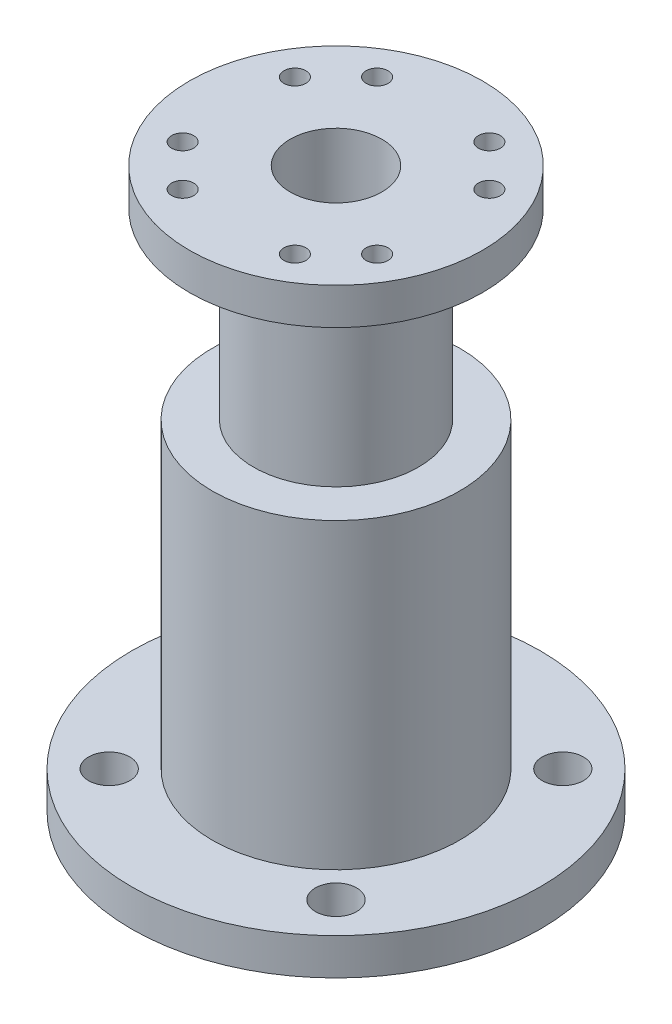
from build123d import *

# Parameters (mm, degrees)
SKETCH2_R                = 22.3
SKETCH2_R_2              = 13.5
BOSS_EXTRUDE1_DEPTH      = 4
M4_CLEARANCE_HOLE1_D     = 4.5
SKETCH6_R                = 16
SKETCH6_R_2              = 9
BOSS_EXTRUDE2_DEPTH      = 4
M2_CLEARANCE_HOLE1_D     = 2.4
M2_CLEARANCE_HOLE1_DEPTH = 4


with BuildPart() as part:
    # Sketch1 → Revolve1 (revolve)
    with BuildSketch(Plane.XY, mode=Mode.PRIVATE) as revolve1_sk:
        Polygon((9, 61), (9, 37), (13.5, 37), (13.5, 0), (9.5, 0), (9.5, 33), (5, 33), (5, 61), align=None)
    revolve(revolve1_sk.sketch.rotate(Axis((0, 0, 0), (0, 1, 0)), 90), axis=Axis((0, 0, 0), (0, 1, 0)))  # turned: the seam where the file's is

    # Sketch2 → Boss-Extrude1 (add)
    with BuildSketch(Plane.XZ):
        with Locations(Location((0, 0, 0), (0, 0, 270))):  # turned: the seam where the file's is
            Circle(SKETCH2_R)
        with Locations(Location((0, 0, 0), (0, 0, 270))):  # turned: the seam where the file's is
            Circle(SKETCH2_R_2, mode=Mode.SUBTRACT)
    extrude(amount=-BOSS_EXTRUDE1_DEPTH)

    # M4 Clearance Hole1 (through all)
    with Locations(Plane.XZ):
        with Locations((-12.374368671, 12.374368671), (12.374368671, 12.374368671), (12.374368671, -12.374368671), (-12.374368671, -12.374368671)):
            Hole(M4_CLEARANCE_HOLE1_D / 2)

    # Sketch6 → Boss-Extrude2 (add)
    with BuildSketch(Plane(origin=(0, 61, 0), x_dir=(1, 0, 0), z_dir=(0, 1, 0))):
        with Locations(Location((0, 0, 0), (0, 0, 270))):  # turned: the seam where the file's is
            Circle(SKETCH6_R)
        with Locations(Location((0, 0, 0), (0, 0, 90))):  # turned: the seam where the file's is
            Circle(SKETCH6_R_2, mode=Mode.SUBTRACT)
    extrude(amount=-BOSS_EXTRUDE2_DEPTH)

    # M2 Clearance Hole1
    with Locations(Plane(origin=(0, 61, 0), x_dir=(-1, 0, 0), z_dir=(0, 1, 0))):
        with Locations((10.608811196, -6.125), (-10.608811196, -6.125), (-6.125, 10.608811196), (6.125, 10.608811196), (10.608811196, 6.125), (6.125, -10.608811196), (-6.125, -10.608811196), (-10.608811196, 6.125)):
            Hole(M2_CLEARANCE_HOLE1_D / 2, depth=M2_CLEARANCE_HOLE1_DEPTH)


solid = part.part
